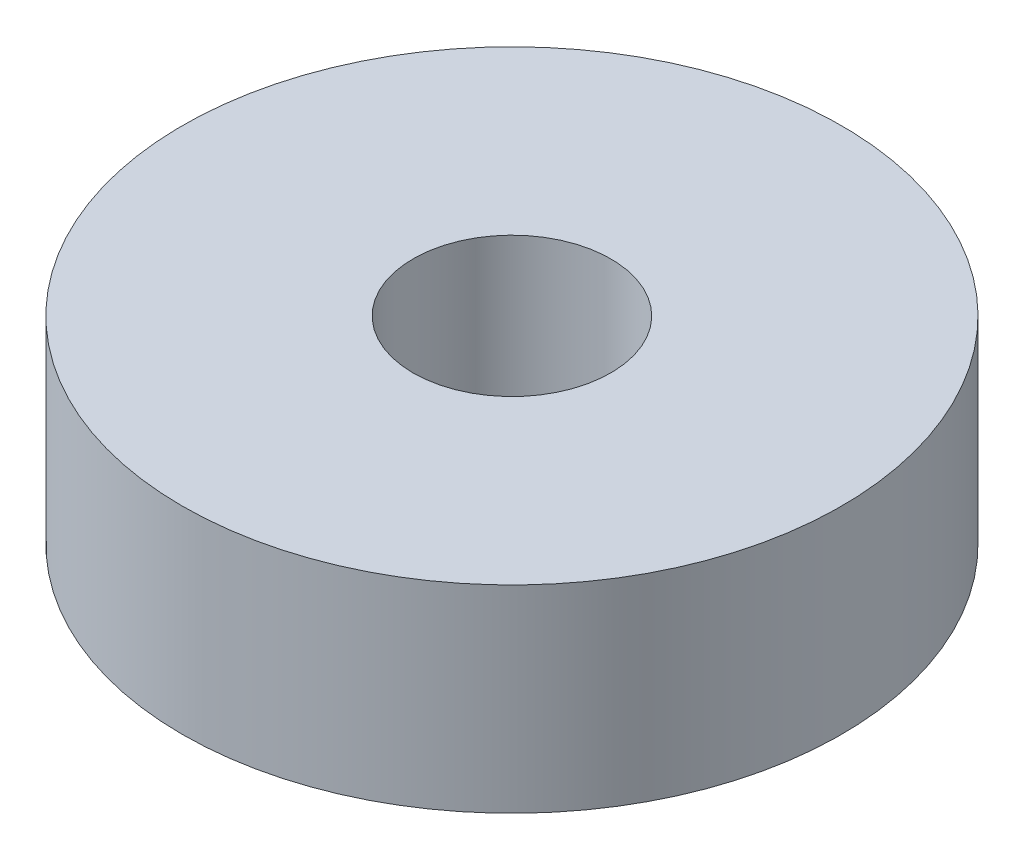
from build123d import *

# Parameters (mm, degrees)
SKETCH1_R           = 5
SKETCH1_R_2         = 1.5
BOSS_EXTRUDE1_DEPTH = 3


with BuildPart() as part:
    # Sketch1 → Boss-Extrude1 (new body)
    with BuildSketch(Plane(origin=(0, 0, 0), x_dir=(1, 0, 0), z_dir=(0, 1, 0))):
        Circle(SKETCH1_R)
        Circle(SKETCH1_R_2, mode=Mode.SUBTRACT)
    extrude(amount=BOSS_EXTRUDE1_DEPTH)


solid = part.part
